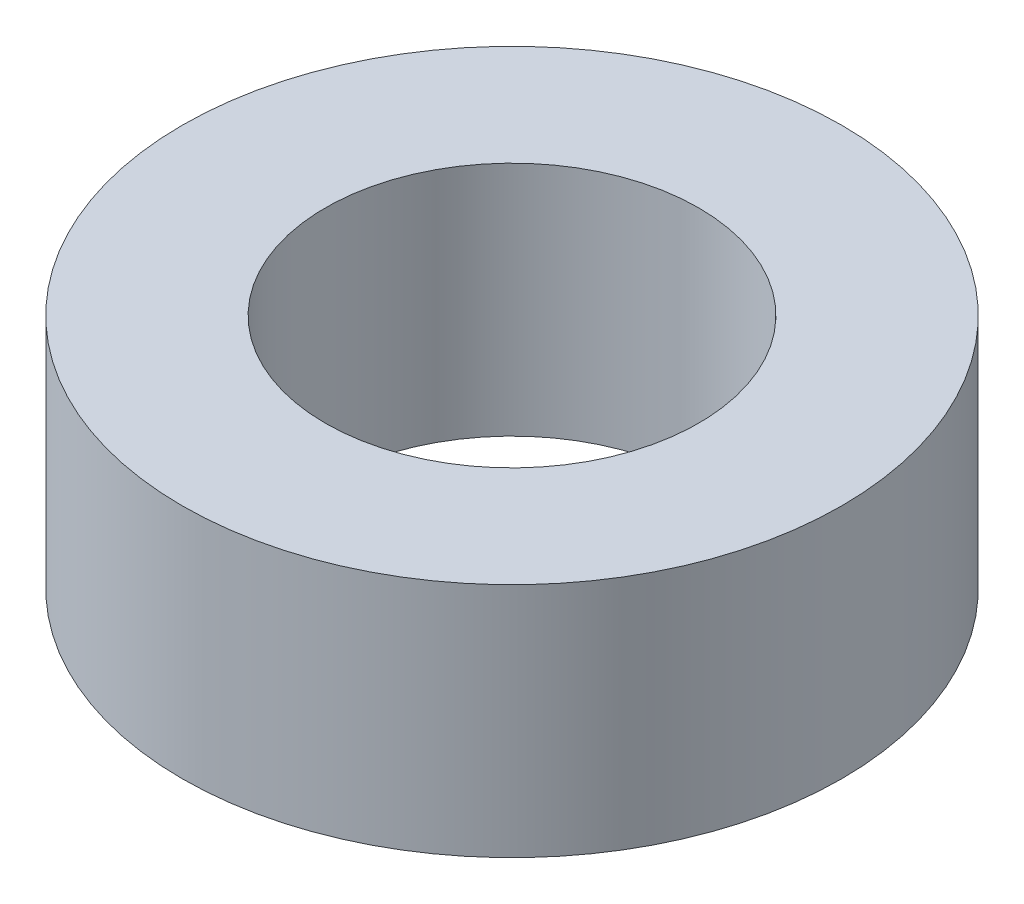
from build123d import *

# Parameters (mm, degrees)
SKETCH1_R           = 5.3
SKETCH1_R_2         = 3
BOSS_EXTRUDE1_DEPTH = 3.8


with BuildPart() as part:
    # Sketch1 → Boss-Extrude1 (new body)
    with BuildSketch(Plane(origin=(0, 0, 0), x_dir=(1, 0, 0), z_dir=(0, 1, 0))):
        Circle(SKETCH1_R)
        Circle(SKETCH1_R_2, mode=Mode.SUBTRACT)
    extrude(amount=BOSS_EXTRUDE1_DEPTH)


solid = part.part
